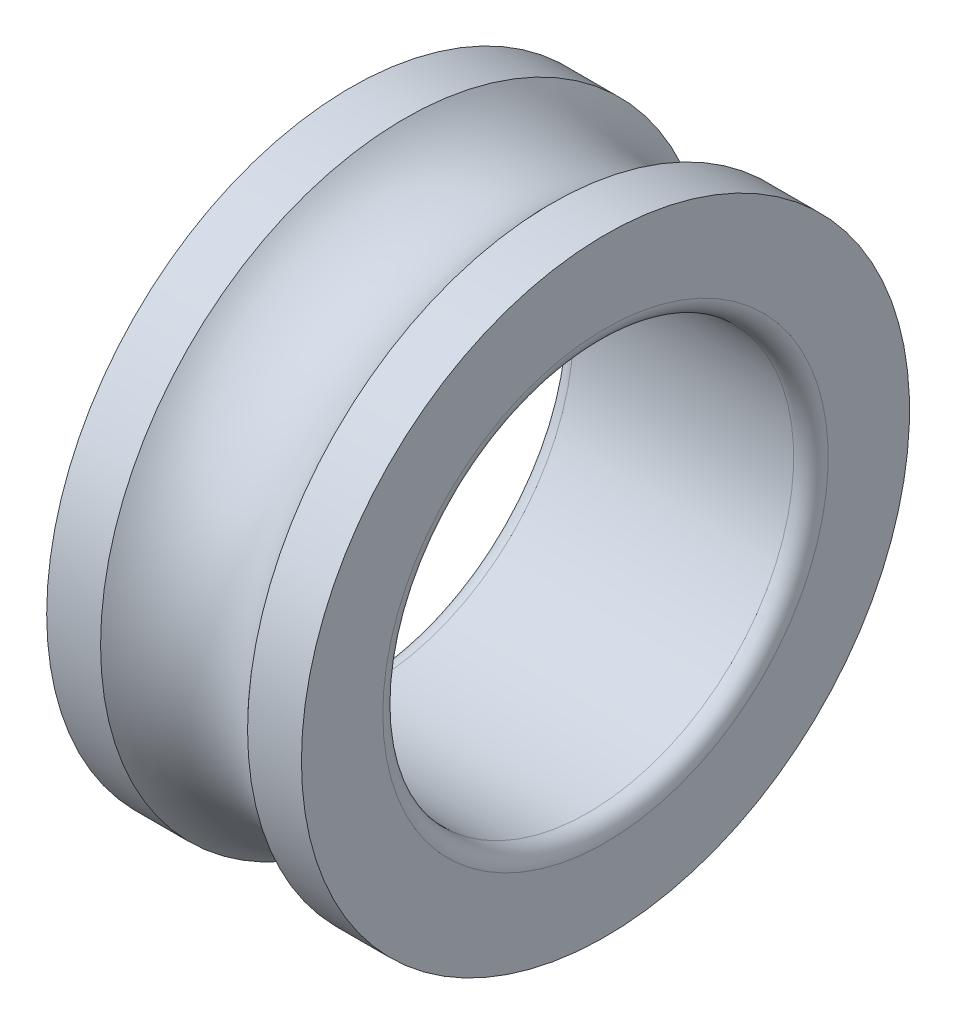
from build123d import *


with BuildPart() as part:
    # Sketch1 → Revolve1 (revolve)
    with BuildSketch(Plane.XY):
        with BuildLine():
            Line((-15.5, 37), (-8.94427191, 37))
            ThreePointArc((-8.94427191, 37), (0, 33), (8.94427191, 37))
            Line((8.94427191, 37), (15.5, 37))
            Line((15.5, 37), (15.5, 27.1))
            ThreePointArc((15.5, 27.1), (14.88492424, 25.61507576), (13.4, 25))
            Line((13.4, 25), (-13.4, 25))
            ThreePointArc((-13.4, 25), (-14.88492424, 25.61507576), (-15.5, 27.1))
            Line((-15.5, 27.1), (-15.5, 37))
        make_face()
    revolve(axis=Axis((-23.455193483, 0, 0), (1, 0, 0)))


solid = part.part
